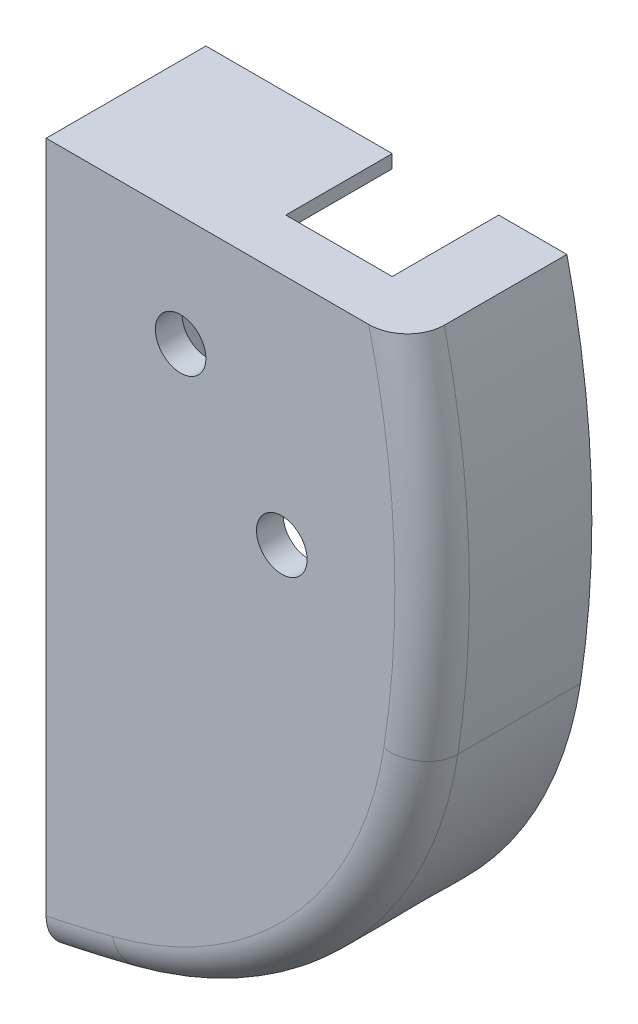
from build123d import *

# Parameters (mm, degrees)
BOSS_EXTRUDE1_DEPTH = 30
CUT_EXTRUDE2_DEPTH  = 20
FILLET1_R           = 7
SKETCH9_W           = 20
SKETCH9_H           = 20
CUT_EXTRUDE7_DEPTH  = 11.0000001
SKETCH10_R          = 4.75
CUT_EXTRUDE8_DEPTH  = 10
CUT_EXTRUDE9_DEPTH  = 20
SKETCH13_R          = 6
CUT_EXTRUDE10_DEPTH = 20
SKETCH14_R          = 9
CUT_EXTRUDE11_DEPTH = 4
CUT_EXTRUDE12_DEPTH = 5
CUT_EXTRUDE13_DEPTH = 30
SKETCH17_R          = 3
CUT_EXTRUDE14_DEPTH = 10
SKETCH18_R          = 3
BOSS_EXTRUDE2_DEPTH = 2.5
CHAMFER1_SIZE       = 1
SKETCH19_W          = 6
SKETCH19_H          = 16
CUT_EXTRUDE15_DEPTH = 6
SKETCH20_R          = 14
BOSS_EXTRUDE3_DEPTH = 16
SKETCH21_R          = 12.5
CUT_EXTRUDE16_DEPTH = 6
SKETCH22_R          = 10.5
CUT_EXTRUDE17_DEPTH = 6


with BuildPart() as part:
    # Sketch1 → Boss-Extrude1 (new body)
    with BuildSketch(Plane.XY):
        with BuildLine():
            Line((0, 0), (67.8, 0))
            ThreePointArc((67.8, 0), (72.369764115, -34.141185106), (70.341123561, -68.527052581))
            ThreePointArc((70.341123561, -68.527052581), (51.546832931, -107.857068487), (14.233546266, -130.391356799))
            ThreePointArc((14.233546266, -130.391356799), (7.138727746, -132.120022188), (0, -133.657325027))
            Line((0, -133.657325027), (0, 0))
        make_face()
    extrude(amount=BOSS_EXTRUDE1_DEPTH)

    # Sketch4 → Cut-Extrude2 (cut)
    with BuildSketch(Plane(origin=(0, 0, 0), x_dir=(-1, 0, 0), z_dir=(0, 0, -1))):
        with BuildLine():
            Line((-10, -121.14971872), (-10, -10))
            Line((-10, -10), (-59.674612632, -10))
            ThreePointArc((-59.674612632, -10), (-62.477031418, -38.458771695), (-60.460886556, -66.98403063))
            ThreePointArc((-60.460886556, -66.98403063), (-44.139528904, -101.139044443), (-11.735885222, -120.708294819))
            ThreePointArc((-11.735885222, -120.708294819), (-10.868320406, -120.930492438), (-10, -121.14971872))
        make_face()
    extrude(amount=-CUT_EXTRUDE2_DEPTH, mode=Mode.SUBTRACT)

    # Fillet1
    fillet1_edges = [part.edges().sort_by_distance(p)[0] for p in [
        (51.546832931, -107.857068487, 30),
        (72.369764115, -34.141185106, 30),
        (7.138727746, -132.120022188, 30),
    ]]
    fillet(fillet1_edges, radius=FILLET1_R)

    # Sketch9 → Cut-Extrude7 (cut, through all)
    with BuildSketch(Plane.XZ.offset(10)):
        with Locations((45, 10)):
            Rectangle(SKETCH9_W, SKETCH9_H)
    extrude(amount=-CUT_EXTRUDE7_DEPTH, mode=Mode.SUBTRACT)

    # Sketch10 → Cut-Extrude8 (cut)
    with BuildSketch(Plane(origin=(0, 0, 20), x_dir=(-1, 0, 0), z_dir=(0, 0, -1))):
        with Locations((-44.259673453, -44.037012246)):
            Circle(SKETCH10_R)
        with Locations((-25.255788876, -20.823818347)):
            Circle(SKETCH10_R)
    extrude(amount=-CUT_EXTRUDE8_DEPTH, mode=Mode.SUBTRACT)

    # Sketch12 → Cut-Extrude9 (cut)
    with BuildSketch(Plane(origin=(0, 0, 0), x_dir=(-1, 0, 0), z_dir=(0, 0, -1))):
        Polygon((-47.057706749, -101.967331088), (-31.861074944, -114.969730167), (-28.21622296, -110.709787578), (-43.412854765, -97.7073885), align=None)
    extrude(amount=-CUT_EXTRUDE9_DEPTH, mode=Mode.SUBTRACT)

    # Sketch13 → Cut-Extrude10 (cut)
    with BuildSketch(Plane(origin=(70.259213318, -82.115876403, 0), x_dir=(0.75983159, 0.650119954, 0), z_dir=(-0.650119954, 0.75983159, 0))):
        with Locations((-40.535064437, -10)):
            Circle(SKETCH13_R)
    extrude(amount=-CUT_EXTRUDE10_DEPTH, mode=Mode.SUBTRACT)

    # Sketch14 → Cut-Extrude11 (cut)
    with BuildSketch(Plane(origin=(75.460172949, -88.194529125, 0), x_dir=(0.75983159, 0.650119954, 0), z_dir=(-0.650119954, 0.75983159, 0))):
        with Locations((-40.535064437, -10)):
            Circle(SKETCH14_R)
    extrude(amount=CUT_EXTRUDE11_DEPTH, mode=Mode.SUBTRACT)

    # Sketch15 → Cut-Extrude12 (cut)
    with BuildSketch(Plane(origin=(0, 0, 20), x_dir=(-1, 0, 0), z_dir=(0, 0, -1))):
        with BuildLine():
            Line((-33.587532893, -37.528908384), (-22.521301807, -55.675572317))
            Line((-22.521301807, -55.675572317), (-43.865582926, -68.691780041))
            Line((-43.865582926, -68.691780041), (-54.931814012, -50.545116108))
            ThreePointArc((-54.931814012, -50.545116108), (-50.767777314, -33.364871686), (-33.587532893, -37.528908384))
        make_face()
        with BuildLine():
            Line((-30.769766454, -32.04193099), (-45.879132419, -24.61530694))
            Line((-45.879132419, -24.61530694), (-34.851177263, -2.179081654))
            Line((-34.851177263, -2.179081654), (-21.017094236, -9.064419223))
            ThreePointArc((-21.017094236, -9.064419223), (-13.749351617, -25.707659213), (-30.769766454, -32.04193099))
        make_face()
    extrude(amount=-CUT_EXTRUDE12_DEPTH, mode=Mode.SUBTRACT)

    # Sketch16 → Cut-Extrude13 (cut)
    with BuildSketch(Plane(origin=(0, 0, 25), x_dir=(-1, 0, 0), z_dir=(0, 0, -1))):
        with BuildLine():
            Line((-21.017094236, -9.064419223), (-34.851177263, -2.179081654))
            Line((-34.851177263, -2.179081654), (-38.235489597, -9.064419223))
            Line((-38.235489597, -9.064419223), (-15.338867846, -20.318670536))
            Line((-15.338867846, -20.318670536), (-14.364449962, -26.958045002))
            ThreePointArc((-14.364449962, -26.958045002), (-13.539350009, -16.467781124), (-21.017094236, -9.064419223))
        make_face()
    extrude(amount=CUT_EXTRUDE13_DEPTH, mode=Mode.SUBTRACT)

    # Sketch17 → Cut-Extrude14 (cut)
    with BuildSketch(Plane.ZY):
        with Locations((10, -73.657325027)):
            Circle(SKETCH17_R)
        with Locations((10, -23.657325027)):
            Circle(SKETCH17_R)
    extrude(amount=-CUT_EXTRUDE14_DEPTH, mode=Mode.SUBTRACT)

    # Sketch18 → Boss-Extrude2 (add)
    with BuildSketch(Plane.ZY):
        Polygon((10, -83.657325027), (2.5, -83.657325027), (2.5, -13.657325027), (17.5, -13.657325027), (17.5, -83.657325027), align=None)
        with Locations((10, -73.657325027)):
            Circle(SKETCH18_R, mode=Mode.SUBTRACT)
        with Locations((10, -23.657325027)):
            Circle(SKETCH18_R, mode=Mode.SUBTRACT)
    extrude(amount=BOSS_EXTRUDE2_DEPTH)

    # Chamfer1
    chamfer1_edges = [part.edges().sort_by_distance(p)[0] for p in [
        (-2.5, -83.657325027, 10),
        (-2.5, -48.657325027, 17.5),
        (-2.5, -13.657325027, 10),
        (-2.5, -48.657325027, 2.5),
        (-1.25, -83.657325027, 17.5),
        (-1.25, -13.657325027, 17.5),
        (-1.25, -13.657325027, 2.5),
        (-1.25, -83.657325027, 2.5),
        (-2.5, -73.657325027, 7),
        (-2.5, -23.657325027, 7),
    ]]
    chamfer(chamfer1_edges, length=CHAMFER1_SIZE)

    # Sketch19 → Cut-Extrude15 (cut)
    with BuildSketch(Plane(origin=(0, 0, 0), x_dir=(-1, 0, 0), z_dir=(0, 0, -1))):
        with Locations((-5, -115.657325027)):
            Rectangle(SKETCH19_W, SKETCH19_H)
    extrude(amount=-CUT_EXTRUDE15_DEPTH, mode=Mode.SUBTRACT)

    # Sketch20 → Boss-Extrude3 (add)
    with BuildSketch(Plane(origin=(0, 0, 0), x_dir=(-1, 0, 0), z_dir=(0, 0, -1))):
        with Locations((-52.341123561, -78.527052581)):
            Circle(SKETCH20_R)
    extrude(amount=-BOSS_EXTRUDE3_DEPTH)

    # Sketch21 → Cut-Extrude16 (cut)
    with BuildSketch(Plane(origin=(0, 0, 0), x_dir=(-1, 0, 0), z_dir=(0, 0, -1))):
        with Locations((-52.341123561, -78.527052581)):
            Circle(SKETCH21_R)
    extrude(amount=-CUT_EXTRUDE16_DEPTH, mode=Mode.SUBTRACT)

    # Sketch22 → Cut-Extrude17 (cut)
    with BuildSketch(Plane(origin=(0, 0, 6), x_dir=(-1, 0, 0), z_dir=(0, 0, -1))):
        with Locations((-52.341123561, -78.527052581)):
            Circle(SKETCH22_R)
    extrude(amount=-CUT_EXTRUDE17_DEPTH, mode=Mode.SUBTRACT)


solid = part.part
